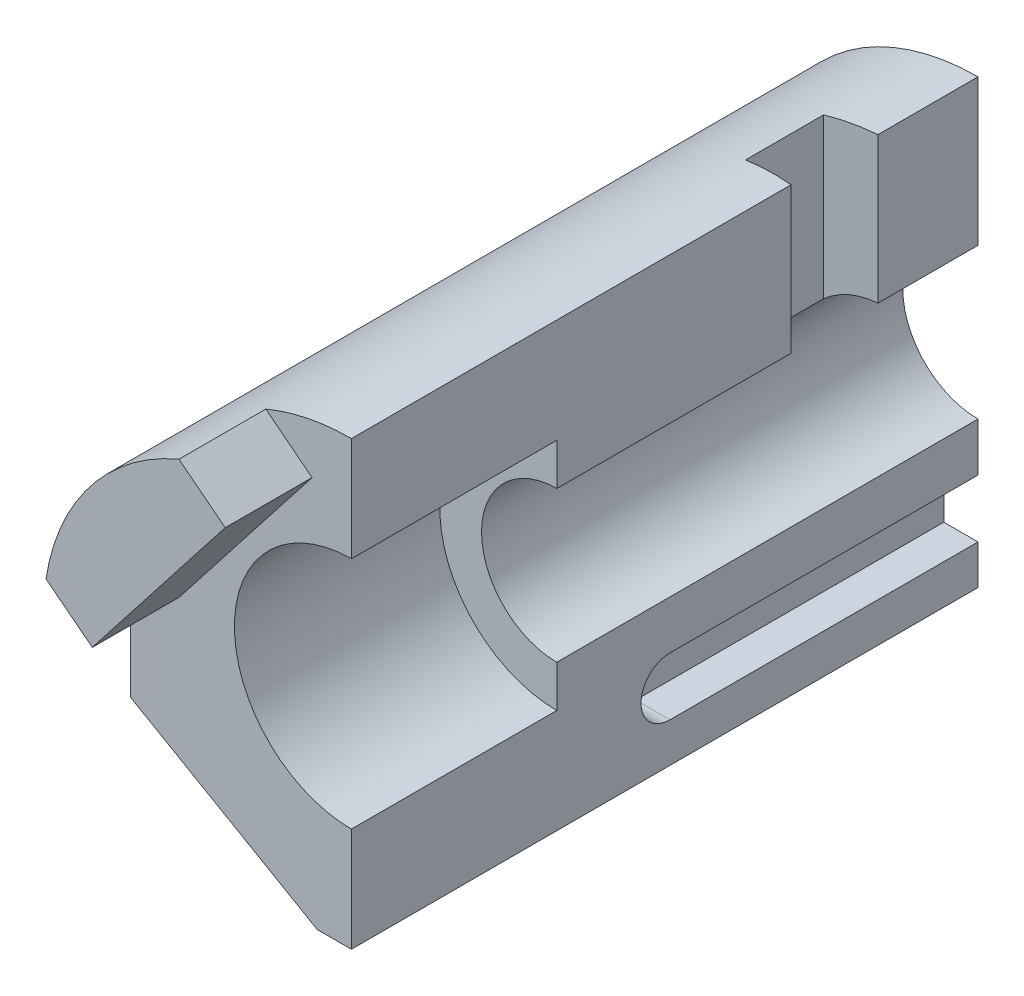
from build123d import *

# Parameters (mm, degrees)
BOSS_EXTRUDE1_DEPTH = 238
SKETCH6_R           = 44.45
CUT_EXTRUDE1_DEPTH  = 78
SKETCH7_W           = 33
SKETCH7_H           = 85
CUT_EXTRUDE2_DEPTH  = 19
CUT_EXTRUDE2_TAPER  = 5
CUT_EXTRUDE3_DEPTH  = 13
BOSS_EXTRUDE2_DEPTH = 33


with BuildPart() as part:
    # Sketch5 → Boss-Extrude1 (new body)
    with BuildSketch(Plane.XY):
        with BuildLine():
            Line((-84, -43.008130888), (-84, 0))
            ThreePointArc((-84, 0), (-59.39696962, 59.39696962), (0, 84))
            Line((0, 84), (0, 28.575))
            ThreePointArc((0, 28.575), (-28.575, 0), (0, -28.575))
            Line((0, -28.575), (0, -84))
            Line((0, -84), (-13, -84))
            Line((-13, -84), (-84, -43.008130888))
        make_face()
    extrude(amount=BOSS_EXTRUDE1_DEPTH)

    # Sketch6 → Cut-Extrude1 (cut)
    with BuildSketch(Plane.XY.offset(238)):
        Circle(SKETCH6_R)
    extrude(amount=-CUT_EXTRUDE1_DEPTH, mode=Mode.SUBTRACT)

    # Sketch7 → Cut-Extrude2 (cut)
    with BuildSketch(Plane(origin=(0, 0, 0), x_dir=(0, 0, -1), z_dir=(1, 0, 0))):
        with Locations((-54.5, 43.5)):
            Rectangle(SKETCH7_W, SKETCH7_H)
    extrude(amount=-CUT_EXTRUDE2_DEPTH, taper=CUT_EXTRUDE2_TAPER, mode=Mode.SUBTRACT)

    # Sketch8 → Cut-Extrude3 (cut)
    with BuildSketch(Plane(origin=(0, 0, 0), x_dir=(0, 0, -1), z_dir=(1, 0, 0))):
        with BuildLine():
            Line((-117, -47), (66, -47))
            ThreePointArc((66, -47), (77, -58), (66, -69))
            Line((66, -69), (-117, -69))
            ThreePointArc((-117, -69), (-128, -58), (-117, -47))
        make_face()
    extrude(amount=-CUT_EXTRUDE3_DEPTH, mode=Mode.SUBTRACT)

    # Sketch9 → Boss-Extrude2 (add)
    with BuildSketch(Plane.XY.offset(238)):
        with BuildLine():
            Line((-83.014649379, 12.828405531), (-65.430668922, -0.909705656))
            Line((-65.430668922, -0.909705656), (-14.946427946, 63.707176139))
            Line((-14.946427946, 63.707176139), (-32.530408402, 77.445287327))
            ThreePointArc((-32.530408402, 77.445287327), (-66.192903303, 51.715563927), (-83.014649379, 12.828405531))
        make_face()
    extrude(amount=BOSS_EXTRUDE2_DEPTH)


solid = part.part
